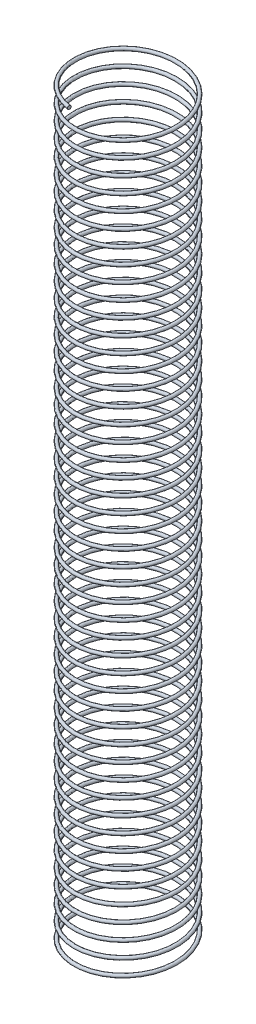
from build123d import *

# Parameters (mm, degrees)
SWEEP1_PITCH       = 45
SWEEP1_HEIGHT      = 2170
SWEEP1_RADIUS      = 150
SWEEP1_START_ANGLE = -90
SKETCH3_R          = 5


with BuildPart() as part:
    # Sweep1: sweep along a helix
    with BuildLine() as sweep1_path:
        add(Helix(SWEEP1_PITCH, SWEEP1_HEIGHT, SWEEP1_RADIUS, center=(0, 0, 0), direction=(0, 1, 0), mode=Mode.PRIVATE).rotate(Axis((0, 0, 0), (0, 1, 0)), SWEEP1_START_ANGLE))
    # Sketch3 → Sweep1 (sweep)
    with BuildSketch(Plane.XY):
        with Locations((-148.15060584, 0)):
            Circle(SKETCH3_R)
    sweep(path=sweep1_path.line, is_frenet=True)


solid = part.part
